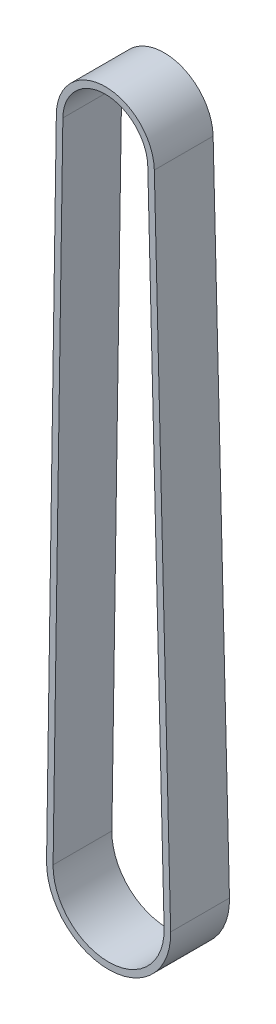
from build123d import *

# Parameters (mm, degrees)
EXTRUDE_THIN1_START = 2
EXTRUDE_THIN1_DEPTH = 9


with BuildPart() as part:
    # Sketch2 → Extrude-Thin1 (new body)
    with BuildSketch(Plane.XY.offset(EXTRUDE_THIN1_START)):
        with BuildLine():
            Line((-8.998926605, -99.647194726), (-7.499152537, 0.112733154))
            ThreePointArc((-7.499152537, 0.112733154), (-0.037578397, 7.499898006), (7.497646347, 0.187874946))
            Line((7.497646347, 0.187874946), (9.997018648, -99.552015124))
            ThreePointArc((9.997018648, -99.552015124), (0.547599362, -109.289880752), (-8.998926605, -99.647194726))
        make_face()
        with BuildLine():
            Line((-7.999039594, -99.66222686), (-6.499265526, 0.09770102))
            ThreePointArc((-6.499265526, 0.09770102), (-0.032567938, 6.499910558), (6.497960174, 0.162823906))
            Line((6.497960174, 0.162823906), (8.997332474, -99.577066164))
            ThreePointArc((8.997332474, -99.577066164), (0.542588903, -108.289893304), (-7.999039594, -99.66222686))
        make_face(mode=Mode.SUBTRACT)
    extrude(amount=-EXTRUDE_THIN1_DEPTH)


solid = part.part
